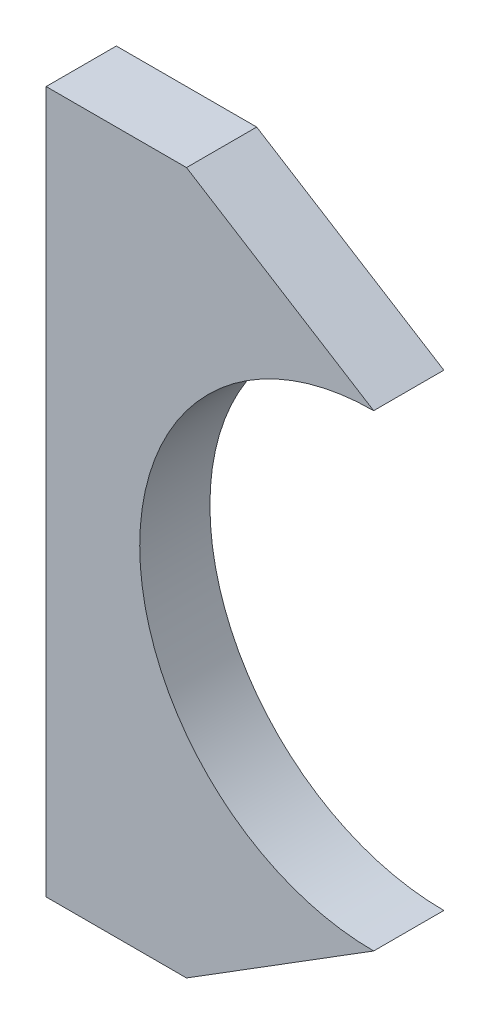
from build123d import *

# Parameters (mm, degrees)
BOSS_EXTRUDE1_DEPTH = 7.5


with BuildPart() as part:
    # Sketch1 → Boss-Extrude1 (new body, symmetric)
    with BuildSketch(Plane.XY):
        with BuildLine():
            Line((0, 50), (-40, 75))
            Line((-40, 75), (-70, 75))
            Line((-70, 75), (-70, -75))
            Line((-70, -75), (-40, -75))
            Line((-40, -75), (0, -50))
            ThreePointArc((0, -50), (-50, 0), (0, 50))
        make_face()
    extrude(amount=BOSS_EXTRUDE1_DEPTH, both=True)


solid = part.part
